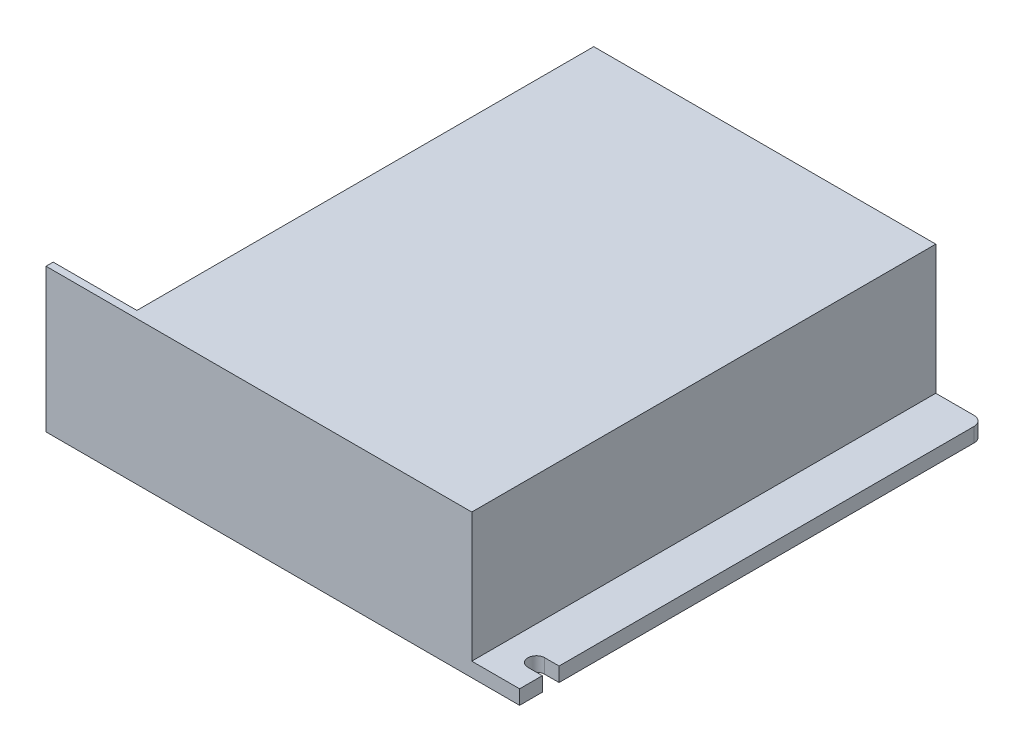
from build123d import *

# Parameters (mm, degrees)
SKETCH2_W           = 99
SKETCH2_H           = 97
BOSS_EXTRUDE1_DEPTH = 3
BOSS_EXTRUDE2_DEPTH = 27
SKETCH5_R           = 1.75
CUT_EXTRUDE1_DEPTH  = 4
FILLET1_R           = 2


with BuildPart() as part:
    # Sketch2 → Boss-Extrude1 (new body)
    with BuildSketch(Plane(origin=(0, 0, 0), x_dir=(1, 0, 0), z_dir=(0, 1, 0))):
        with Locations((49.5, 48.5)):
            Rectangle(SKETCH2_W, SKETCH2_H)
    extrude(amount=BOSS_EXTRUDE1_DEPTH)

    # Sketch4 → Boss-Extrude2 (add)
    with BuildSketch(Plane(origin=(0, 3, 0), x_dir=(1, 0, 0), z_dir=(0, 1, 0))):
        Polygon((17.5, 97), (89, 97), (89, 0), (17.5, 0), (0, 0), (0, 1.5), (17.5, 1.5), align=None)
    extrude(amount=BOSS_EXTRUDE2_DEPTH)

    # Sketch5 → Cut-Extrude1 (cut, through all)
    with BuildSketch(Plane(origin=(0, 3, 0), x_dir=(1, 0, 0), z_dir=(0, 1, 0))):
        with Locations((3.5, 91.5)):
            Circle(SKETCH5_R)
        with BuildLine():
            Line((96, 8.25), (99, 8.25))
            Line((99, 8.25), (99, 4.75))
            Line((99, 4.75), (96, 4.75))
            ThreePointArc((96, 4.75), (94.25, 6.5), (96, 8.25))
        make_face()
    extrude(amount=-CUT_EXTRUDE1_DEPTH, mode=Mode.SUBTRACT)

    # Fillet1
    fillet1_edges = [part.edges().sort_by_distance(p)[0] for p in [
        (0, 1.5, -97),
        (99, 1.5, -97),
    ]]
    fillet(fillet1_edges, radius=FILLET1_R)


solid = part.part
